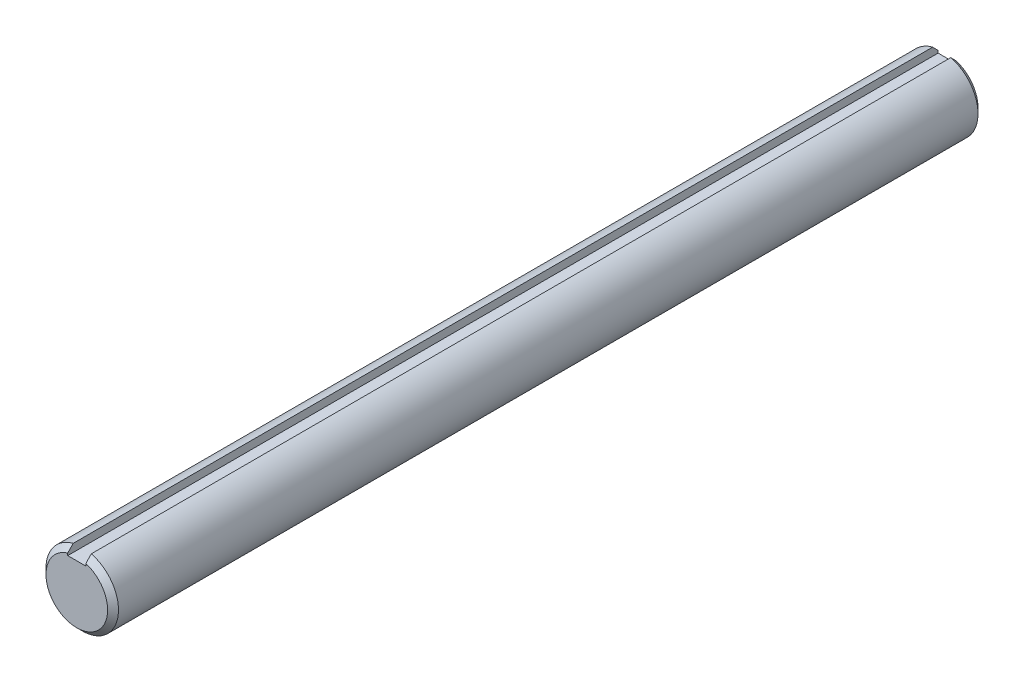
from build123d import *

# Parameters (mm, degrees)
SKETCH1_R           = 6.35
EXTRUDE1_DEPTH      = 76.2
CHAMFER1_SIZE       = 0.9525
SKETCH3_W           = 3.175
SKETCH3_H           = 1.5875
EXTRUDE2_DEPTH      = 77.2
EXTRUDE2_DEPTH_BACK = 77.2


with BuildPart() as part:
    # Sketch1 → Extrude1 (new body, symmetric)
    with BuildSketch(Plane.XY):
        Circle(SKETCH1_R)
    extrude(amount=EXTRUDE1_DEPTH, both=True)

    # Chamfer1
    chamfer1_edges = [part.edges().sort_by_distance(p)[0] for p in [
        (-6.35, 0, -76.2),
        (-6.35, 0, 76.2),
    ]]
    chamfer(chamfer1_edges, length=CHAMFER1_SIZE)

    # Sketch3 → Extrude2 (cut, two sides)
    with BuildSketch(Plane.XY) as extrude2_sk:
        with Locations((0, 5.55625)):
            Rectangle(SKETCH3_W, SKETCH3_H)
    extrude(amount=EXTRUDE2_DEPTH, mode=Mode.SUBTRACT)
    extrude(extrude2_sk.sketch, amount=-EXTRUDE2_DEPTH_BACK, mode=Mode.SUBTRACT)


solid = part.part
